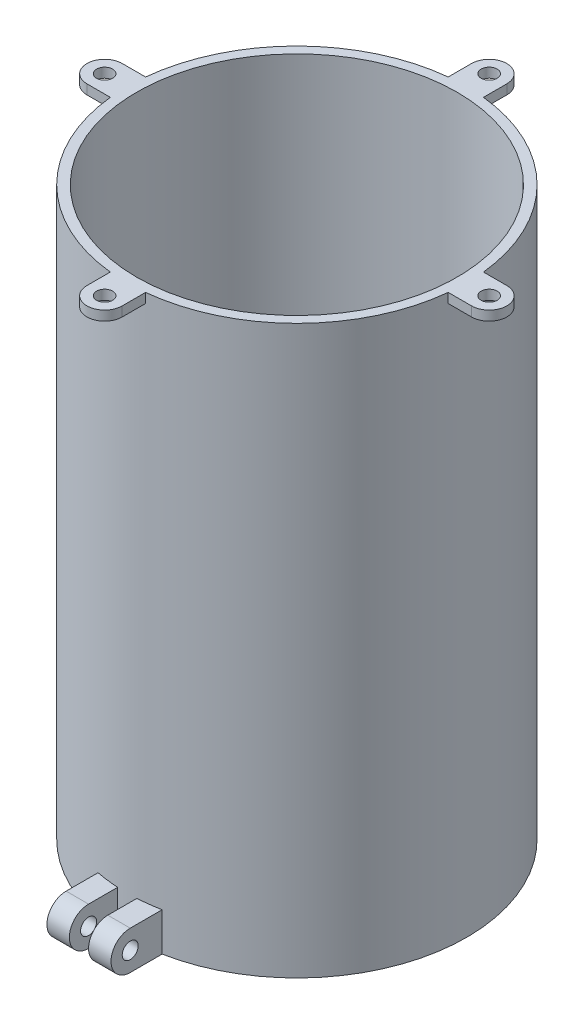
from build123d import *

# Parameters (mm, degrees)
CROQUIS1_R                   = 53
CROQUIS1_R_2                 = 50
SALIENTE_EXTRUIR1_DEPTH      = 176.9
CROQUIS5_R                   = 2.5
SALIENTE_EXTRUIR4_DEPTH      = 3
CROQUIS7_W                   = 7
CROQUIS7_H                   = 12
SALIENTE_EXTRUIR5_DEPTH      = 15
SALIENTE_EXTRUIR5_DEPTH_BACK = 2
CROQUIS8_R                   = 2.5
CORTAR_EXTRUIR1_DEPTH        = 20


with BuildPart() as part:
    # Croquis1 → Saliente-Extruir1 (new body)
    with BuildSketch(Plane(origin=(0, 0, 0), x_dir=(1, 0, 0), z_dir=(0, 1, 0))):
        Circle(CROQUIS1_R)
        Circle(CROQUIS1_R_2, mode=Mode.SUBTRACT)
    extrude(amount=SALIENTE_EXTRUIR1_DEPTH)

    # Croquis5 → Saliente-Extruir4 (add)
    with BuildSketch(Plane(origin=(0, 176.9, 0), x_dir=(1, 0, 0), z_dir=(0, 1, 0))):
        with BuildLine():
            ThreePointArc((-52.713850172, -5.5), (-53, 0), (-52.713850172, 5.5))
            Line((-52.713850172, 5.5), (-60, 5.5))
            ThreePointArc((-60, 5.5), (-65.5, 0), (-60, -5.5))
            Line((-60, -5.5), (-52.713850172, -5.5))
        make_face()
        with Locations((-60, 0)):
            Circle(CROQUIS5_R, mode=Mode.SUBTRACT)
        with BuildLine():
            ThreePointArc((-5.5, 52.713850172), (0, 53), (5.5, 52.713850172))
            Line((5.5, 52.713850172), (5.5, 60))
            ThreePointArc((5.5, 60), (0, 65.5), (-5.5, 60))
            Line((-5.5, 60), (-5.5, 52.713850172))
        make_face()
        with Locations((0, 60)):
            Circle(CROQUIS5_R, mode=Mode.SUBTRACT)
        with BuildLine():
            ThreePointArc((60, -5.5), (65.5, 0), (60, 5.5))
            Line((60, 5.5), (52.713850172, 5.5))
            ThreePointArc((52.713850172, 5.5), (52.928414199, 2.753719381), (53, 0))
            ThreePointArc((53, 0), (52.928414199, -2.753719381), (52.713850172, -5.5))
            Line((52.713850172, -5.5), (60, -5.5))
        make_face()
        with Locations((60, 0)):
            Circle(CROQUIS5_R, mode=Mode.SUBTRACT)
        with BuildLine():
            Line((5.5, -60), (5.5, -52.713850172))
            ThreePointArc((5.5, -52.713850172), (0, -53), (-5.5, -52.713850172))
            Line((-5.5, -52.713850172), (-5.5, -60))
            ThreePointArc((-5.5, -60), (0, -65.5), (5.5, -60))
        make_face()
        with Locations((0, -60)):
            Circle(CROQUIS5_R, mode=Mode.SUBTRACT)
    extrude(amount=-SALIENTE_EXTRUIR4_DEPTH)

    # Croquis7 → Saliente-Extruir5 (add, two sides)
    with BuildSketch(Plane.XY.offset(53)) as saliente_extruir5_sk:
        with Locations((-6.5, 6)):
            Rectangle(CROQUIS7_W, CROQUIS7_H)
        with Locations((6.5, 6)):
            Rectangle(CROQUIS7_W, CROQUIS7_H)
    extrude(amount=SALIENTE_EXTRUIR5_DEPTH)
    extrude(saliente_extruir5_sk.sketch, amount=-SALIENTE_EXTRUIR5_DEPTH_BACK)

    # Croquis8 → Cortar-Extruir1 (cut)
    with BuildSketch(Plane.ZY.offset(10)):
        with Locations((62, 6)):
            Circle(CROQUIS8_R)
        with BuildLine():
            ThreePointArc((62, 12), (66.242640687, 10.242640687), (68, 6))
            Line((68, 6), (68, 12))
            Line((68, 12), (62, 12))
        make_face()
        with BuildLine():
            ThreePointArc((68, 6), (66.242640687, 1.757359313), (62, 0))
            Line((62, 0), (68, 0))
            Line((68, 0), (68, 6))
        make_face()
    extrude(amount=-CORTAR_EXTRUIR1_DEPTH, mode=Mode.SUBTRACT)


solid = part.part
